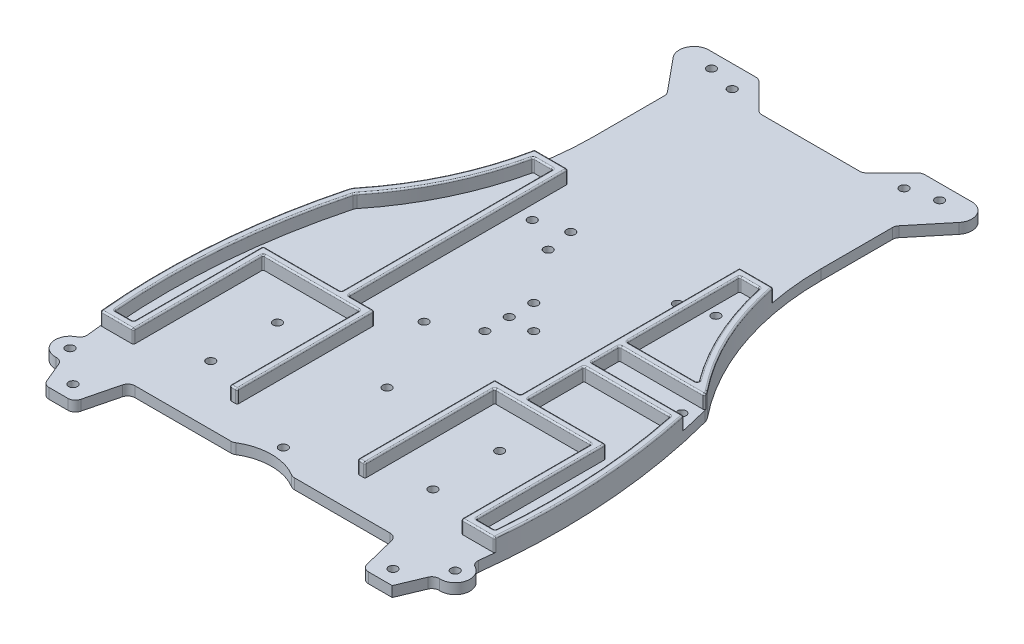
from build123d import *

# Parameters (mm, degrees)
SKETCH1_R                                         = 5
BOSS_EXTRUDE1_DEPTH                               = 8
CSK_FOR_M2_5_FLAT_HEAD_MACHINE_SCREW1_D           = 2.9
CSK_FOR_M2_5_FLAT_HEAD_MACHINE_SCREW1_CSINK_D     = 5.5
CSK_FOR_M2_5_FLAT_HEAD_MACHINE_SCREW1_CSINK_ANGLE = 90
CSK_FOR_M2_5_FLAT_HEAD_MACHINE_SCREW2_D           = 2.9
CSK_FOR_M2_5_FLAT_HEAD_MACHINE_SCREW2_CSINK_D     = 5.5
CSK_FOR_M2_5_FLAT_HEAD_MACHINE_SCREW2_CSINK_ANGLE = 90
FILLET1_R                                         = 2.5
FILLET2_R                                         = 5
CUT_EXTRUDE1_DEPTH                                = 4.5
SKETCH9_R                                         = 1.45
CUT_EXTRUDE3_DEPTH                                = 4.5
FILLET3_R                                         = 0.5


with BuildPart() as part:
    # Sketch1 → Boss-Extrude1 (new body)
    with BuildSketch(Plane(origin=(0, 0, 0), x_dir=(1, 0, 0), z_dir=(0, 1, 0))):
        with Locations((65, -94)):
            Circle(SKETCH1_R)
        with BuildLine():
            Line((58.75, -109), (65, -94))
            ThreePointArc((65, -94), (67.161469468, -48.741029474), (60, -4))
            ThreePointArc((60, -4), (44.037279914, 24.132108636), (38.5, 56))
            Line((38.5, 56), (38.5, 81))
            Line((38.5, 81), (55, 101))
            Line((55, 101), (27.5, 101))
            Line((27.5, 101), (17.5, 91))
            Line((17.5, 91), (0, 91))
            Line((0, 91), (0, -91))
            ThreePointArc((0, -91), (5.220153254, -91.766155818), (10, -94))
            Line((10, -94), (45, -94))
            Line((45, -94), (48.75, -109))
            Line((48.75, -109), (58.75, -109))
        make_face()
    boss_extrude1 = extrude(amount=BOSS_EXTRUDE1_DEPTH)

    # CSK for M2.5 Flat Head Machine Screw1 (through all)
    with Locations(Plane(origin=(0, 0, 0), x_dir=(-1, 0, 0), z_dir=(0, -1, 0))):
        with Locations((-65, -94), (-54, -104), (0, -87), (0, -52), (-37.5, -51.5), (-37.5, -74), (0, -19), (0, -10.75), (0, -2.5), (-24.5, 21.5), (-29, 93.5), (-38.5, 96)):
            csk_for_m2_5_flat_head_machine_screw1 = CounterSinkHole(CSK_FOR_M2_5_FLAT_HEAD_MACHINE_SCREW1_D / 2, CSK_FOR_M2_5_FLAT_HEAD_MACHINE_SCREW1_CSINK_D / 2, counter_sink_angle=CSK_FOR_M2_5_FLAT_HEAD_MACHINE_SCREW1_CSINK_ANGLE)

    # Mirror1: Boss-Extrude1, CSK for M2.5 Flat Head Machine Screw1 across plane
    add(boss_extrude1.mirror(Plane(origin=(0, 0, 0), x_dir=(0, 0, 1), z_dir=(1, 0, 0))))
    add(csk_for_m2_5_flat_head_machine_screw1.mirror(Plane(origin=(0, 0, 0), x_dir=(0, 0, 1), z_dir=(1, 0, 0))), mode=Mode.SUBTRACT)

    # CSK for M2.5 Flat Head Machine Screw2 (through all)
    with Locations(Plane(origin=(0, 0, 0), x_dir=(-1, 0, 0), z_dir=(0, -1, 0))):
        with Locations((-8.25, -10.75), (13, -26.5), (13.1, 15.5), (14.5, 24.5), (-34.5, 24.5), (-57.25, -9.75)):
            CounterSinkHole(CSK_FOR_M2_5_FLAT_HEAD_MACHINE_SCREW2_D / 2, CSK_FOR_M2_5_FLAT_HEAD_MACHINE_SCREW2_CSINK_D / 2, counter_sink_angle=CSK_FOR_M2_5_FLAT_HEAD_MACHINE_SCREW2_CSINK_ANGLE)

    # Fillet1
    fillet1_edges = [part.edges().sort_by_distance(p)[0] for p in [
        (-63.076923077, 4, 98.615384615),
        (-58.75, 4, 109),
        (-48.75, 4, 109),
        (-45, 4, 94),
        (-10, 4, 94),
        (-17.5, 4, -91),
        (-27.5, 4, -101),
        (-38.5, 4, -81),
        (-65.695592958, 4, 89.04862136),
        (48.75, 4, 109),
        (45, 4, 94),
        (10, 4, 94),
        (17.5, 4, -91),
        (27.5, 4, -101),
        (38.5, 4, -81),
        (65.695592958, 4, 89.04862136),
        (63.076923077, 4, 98.615384615),
    ]]
    fillet(fillet1_edges, radius=FILLET1_R)

    # Fillet2
    fillet2_edges = [part.edges().sort_by_distance(p)[0] for p in [
        (-55, 4, -101),
        (-60, 4, 4),
        (55, 4, -101),
        (60, 4, 4),
    ]]
    fillet(fillet2_edges, radius=FILLET2_R)

    # Sketch8 → Cut-Extrude1 (cut)
    with BuildSketch(Plane(origin=(0, 8, 0), x_dir=(1, 0, 0), z_dir=(0, 1, 0))):
        with BuildLine():
            ThreePointArc((-38.5, 56), (-38.93366178, 46.958495647), (-40.230665735, 38))
            Line((-40.230665735, 38), (40.230665735, 38))
            ThreePointArc((40.230665735, 38), (38.93366178, 46.958495647), (38.5, 56))
            Line((38.5, 56), (38.5, 80.10185086))
            ThreePointArc((38.5, 80.10185086), (38.64722685, 80.947107333), (39.071566804, 81.692808247))
            Line((39.071566804, 81.692808247), (48.249920311, 92.818085226))
            ThreePointArc((48.249920311, 92.818085226), (48.915750784, 98.131950531), (44.393053919, 101))
            Line((44.393053919, 101), (28.535533906, 101))
            ThreePointArc((28.535533906, 101), (27.578825325, 100.809698831), (26.767766953, 100.267766953))
            Line((26.767766953, 100.267766953), (18.232233047, 91.732233047))
            ThreePointArc((18.232233047, 91.732233047), (17.421174675, 91.190301169), (16.464466094, 91))
            Line((16.464466094, 91), (-16.464466094, 91))
            ThreePointArc((-16.464466094, 91), (-17.421174675, 91.190301169), (-18.232233047, 91.732233047))
            Line((-18.232233047, 91.732233047), (-26.767766953, 100.267766953))
            ThreePointArc((-26.767766953, 100.267766953), (-27.578825325, 100.809698831), (-28.535533906, 101))
            Line((-28.535533906, 101), (-44.393053919, 101))
            ThreePointArc((-44.393053919, 101), (-48.915750784, 98.131950531), (-48.249920311, 92.818085226))
            Line((-48.249920311, 92.818085226), (-39.071566804, 81.692808247))
            ThreePointArc((-39.071566804, 81.692808247), (-38.64722685, 80.947107333), (-38.5, 80.10185086))
            Line((-38.5, 80.10185086), (-38.5, 56))
        make_face()
    extrude(amount=-CUT_EXTRUDE1_DEPTH, mode=Mode.SUBTRACT)

    # Sketch9 → Cut-Extrude3 (cut)
    with BuildSketch(Plane(origin=(0, 8, 0), x_dir=(1, 0, 0), z_dir=(0, 1, 0))):
        with BuildLine():
            Line((20.332789423, -36), (28.980665735, -36))
            Line((28.980665735, -36), (28.980665735, 38))
            Line((28.980665735, 38), (-28.980665735, 38))
            Line((-28.980665735, 38), (-28.980665735, -36))
            Line((-28.980665735, -36), (-20.332789423, -36))
            Line((-20.332789423, -36), (-20.332789423, -82.25))
            Line((-20.332789423, -82.25), (-22.832789423, -82.25))
            Line((-22.832789423, -82.25), (-22.832789423, -38.5))
            Line((-22.832789423, -38.5), (-55.332789423, -38.5))
            Line((-55.332789423, -38.5), (-55.332789423, -82.25))
            Line((-55.332789423, -82.25), (-66.464655839, -82.25))
            ThreePointArc((-66.464655839, -82.25), (-66.218407293, -84.642779026), (-65.945997096, -87.03272097))
            add(Edge.make_bspline(
                [(-65.945997096, -87.03272097), (-65.931819599, -87.151334825), (-65.924217217, -87.272654234), (-65.923675828, -87.396066101), (-65.930592061, -87.52084183), (-65.945223783, -87.646157242), (-65.990231169, -87.896877325), (-66.020700469, -88.022280978), (-66.059160673, -88.146473288), (-66.10553398, -88.268536553), (-66.159553485, -88.387576343), (-66.28201978, -88.617983577), (-66.350468204, -88.729354092), (-66.425700267, -88.836078322), (-66.507123916, -88.937434656), (-66.594022018, -89.032845213), (-66.776658425, -89.210412573), (-66.872343503, -89.29264642), (-66.971897579, -89.368183185), (-67.074493251, -89.436775533), (-67.179304716, -89.498344615), (-67.285551979, -89.552950175)],
                knots=[0, 0, 0, 0, 0, 0, 0, 0.249259064, 0.249259064, 0.249259064, 0.249259064, 0.249259064, 0.5, 0.5, 0.5, 0.5, 0.5, 0.750740936, 0.750740936, 0.750740936, 0.750740936, 0.750740936, 1, 1, 1, 1, 1, 1, 1], degree=6))
            ThreePointArc((-67.285551979, -89.552950175), (-69.825660331, -95.308817165), (-64.725367228, -98.992451987))
            ThreePointArc((-64.725367228, -98.992451987), (-63.258972452, -99.371238339), (-62.280358534, -100.527139519))
            Line((-62.280358534, -100.527139519), (-59.391025641, -107.461538462))
            ThreePointArc((-59.391025641, -107.461538462), (-58.470083824, -108.580125736), (-57.083333333, -109))
            Line((-57.083333333, -109), (-50.701941016, -109))
            ThreePointArc((-50.701941016, -109), (-49.163410493, -108.470513595), (-48.276584766, -107.106339063))
            Line((-48.276584766, -107.106339063), (-45.473415234, -95.893660937))
            ThreePointArc((-45.473415234, -95.893660937), (-44.586589507, -94.529486405), (-43.048058984, -94))
            Line((-43.048058984, -94), (-10.723805295, -94))
            ThreePointArc((-10.723805295, -94), (-10.050285412, -93.907565361), (-9.426570783, -93.637096774))
            ThreePointArc((-9.426570783, -93.637096774), (0, -91), (9.426570783, -93.637096774))
            ThreePointArc((9.426570783, -93.637096774), (10.050285412, -93.907565361), (10.723805295, -94))
            Line((10.723805295, -94), (43.048058984, -94))
            ThreePointArc((43.048058984, -94), (44.586589507, -94.529486405), (45.473415234, -95.893660937))
            Line((45.473415234, -95.893660937), (48.276584766, -107.106339063))
            ThreePointArc((48.276584766, -107.106339063), (49.163410493, -108.470513595), (50.701941016, -109))
            Line((50.701941016, -109), (58.75, -109))
            Line((58.75, -109), (62.280358534, -100.527139519))
            ThreePointArc((62.280358534, -100.527139519), (63.258972452, -99.371238339), (64.725367228, -98.992451987))
            ThreePointArc((64.725367228, -98.992451987), (69.825660331, -95.308817165), (67.285551979, -89.552950175))
            add(Edge.make_bspline(
                [(67.285551979, -89.552950175), (67.179304716, -89.498344615), (67.074493251, -89.436775533), (66.971897579, -89.368183185), (66.872343503, -89.29264642), (66.776658425, -89.210412573), (66.594022018, -89.032845213), (66.507123916, -88.937434656), (66.425700267, -88.836078322), (66.350468204, -88.729354092), (66.28201978, -88.617983577), (66.159553485, -88.387576343), (66.10553398, -88.268536553), (66.059160673, -88.146473288), (66.020700469, -88.022280978), (65.990231169, -87.896877325), (65.945223783, -87.646157242), (65.930592061, -87.52084183), (65.923675828, -87.396066101), (65.924217217, -87.272654234), (65.931819599, -87.151334825), (65.945997096, -87.03272097)],
                knots=[0, 0, 0, 0, 0, 0, 0, 0.249259064, 0.249259064, 0.249259064, 0.249259064, 0.249259064, 0.5, 0.5, 0.5, 0.5, 0.5, 0.750740936, 0.750740936, 0.750740936, 0.750740936, 0.750740936, 1, 1, 1, 1, 1, 1, 1], degree=6))
            ThreePointArc((65.945997096, -87.03272097), (66.218407293, -84.642779026), (66.464655839, -82.25))
            Line((66.464655839, -82.25), (55.332789423, -82.25))
            Line((55.332789423, -82.25), (55.332789423, -38.5))
            Line((55.332789423, -38.5), (22.832789423, -38.5))
            Line((22.832789423, -38.5), (22.832789423, -82.25))
            Line((22.832789423, -82.25), (20.332789423, -82.25))
            Line((20.332789423, -82.25), (20.332789423, -36))
        make_face()
        with Locations(Location((0, -52, 0), (0, 0, 90))):
            Circle(SKETCH9_R, mode=Mode.SUBTRACT)
        with Locations(Location((-13, -26.5, 0), (0, 0, 90))):
            Circle(SKETCH9_R, mode=Mode.SUBTRACT)
        with Locations(Location((-13.1, 15.5, 0), (0, 0, 90))):
            Circle(SKETCH9_R, mode=Mode.SUBTRACT)
        with Locations(Location((-24.5, 21.5, 0), (0, 0, 90))):
            Circle(SKETCH9_R, mode=Mode.SUBTRACT)
        with Locations(Location((-14.5, 24.5, 0), (0, 0, 90))):
            Circle(SKETCH9_R, mode=Mode.SUBTRACT)
        with Locations(Location((0, -19, 0), (0, 0, 90))):
            Circle(SKETCH9_R, mode=Mode.SUBTRACT)
        with Locations(Location((0, -10.75, 0), (0, 0, 90))):
            Circle(SKETCH9_R, mode=Mode.SUBTRACT)
        with Locations(Location((8.25, -10.75, 0), (0, 0, 90))):
            Circle(SKETCH9_R, mode=Mode.SUBTRACT)
        with Locations(Location((0, -2.5, 0), (0, 0, 90))):
            Circle(SKETCH9_R, mode=Mode.SUBTRACT)
        with Locations(Location((24.5, 21.5, 0), (0, 0, 90))):
            Circle(SKETCH9_R, mode=Mode.SUBTRACT)
        with Locations(Location((65, -94, 0), (0, 0, 90))):
            Circle(SKETCH9_R, mode=Mode.SUBTRACT)
        with Locations(Location((-54, -104, 0), (0, 0, 90))):
            Circle(SKETCH9_R, mode=Mode.SUBTRACT)
        with Locations(Location((-65, -94, 0), (0, 0, 90))):
            Circle(SKETCH9_R, mode=Mode.SUBTRACT)
        with Locations(Location((0, -87, 0), (0, 0, 90))):
            Circle(SKETCH9_R, mode=Mode.SUBTRACT)
        with Locations(Location((54, -104, 0), (0, 0, 90))):
            Circle(SKETCH9_R, mode=Mode.SUBTRACT)
        with Locations(Location((37.5, -51.5, 0), (0, 0, 90))):
            Circle(SKETCH9_R, mode=Mode.SUBTRACT)
        with Locations(Location((37.5, -74, 0), (0, 0, 90))):
            Circle(SKETCH9_R, mode=Mode.SUBTRACT)
        with Locations(Location((-37.5, -51.5, 0), (0, 0, 90))):
            Circle(SKETCH9_R, mode=Mode.SUBTRACT)
        with Locations(Location((-37.5, -74, 0), (0, 0, 90))):
            Circle(SKETCH9_R, mode=Mode.SUBTRACT)
        with BuildLine():
            Line((31.480665735, -17), (31.480665735, -36))
            Line((31.480665735, -36), (57.832789423, -36))
            Line((57.832789423, -36), (57.832789423, -79.75))
            Line((57.832789423, -79.75), (64.184419432, -79.75))
            ThreePointArc((64.184419432, -79.75), (64.628927323, -48.241601045), (60.513206722, -17))
            Line((60.513206722, -17), (31.480665735, -17))
        make_face()
        with BuildLine():
            Line((38.191653436, 35.5), (31.480665735, 35.5))
            Line((31.480665735, 35.5), (31.480665735, -2.5))
            Line((31.480665735, -2.5), (55.633285388, -2.5))
            ThreePointArc((55.633285388, -2.5), (44.840012395, 15.548762302), (38.191653436, 35.5))
        make_face()
        with Locations(Location((34.5, 24.5, 0), (0, 0, 90))):
            Circle(SKETCH9_R, mode=Mode.SUBTRACT)
        with BuildLine():
            Line((31.480665735, -5), (31.480665735, -14.5))
            Line((31.480665735, -14.5), (62.540277173, -14.5))
            ThreePointArc((62.540277173, -14.5), (61.461684719, -9.762400864), (60.278670109, -5.049791854))
            add(Edge.make_bspline(
                [(60.278670109, -5.049791854), (60.276050659, -5.039824786), (60.273404865, -5.029861931), (60.270732733, -5.019903425), (60.268034272, -5.009949402), (60.265309493, -4.999999999)],
                knots=[0, 0, 0, 0, 0, 0, 0.024701767, 0.024701767, 0.024701767, 0.024701767, 0.024701767, 0.024701767], degree=5))
            Line((60.265309489, -5), (31.480665735, -5))
        make_face()
        with Locations(Location((57.25, -9.75, 0), (0, 0, 90))):
            Circle(SKETCH9_R, mode=Mode.SUBTRACT)
        with BuildLine():
            Line((-31.480665735, -36), (-31.480665735, 35.5))
            Line((-31.480665735, 35.5), (-38.191653436, 35.5))
            ThreePointArc((-38.191653436, 35.5), (-45.445876078, 14.254027674), (-57.391394339, -4.754383087))
            ThreePointArc((-57.391394339, -4.754383087), (-57.675145926, -5.195072769), (-57.86077716, -5.68523948))
            ThreePointArc((-57.86077716, -5.68523948), (-64.212001626, -42.445308784), (-64.184419432, -79.75))
            Line((-64.184419432, -79.75), (-57.832789423, -79.75))
            Line((-57.832789423, -79.75), (-57.832789423, -36))
            Line((-57.832789423, -36), (-31.480665735, -36))
        make_face()
    extrude(amount=-CUT_EXTRUDE3_DEPTH, mode=Mode.SUBTRACT)

    # Fillet3
    fillet3_edges = [part.edges().sort_by_distance(p)[0] for p in [
        (-59.907407641, 8, 4.069458433),
        (-47.273987345, 8, -16.240842076),
        (47.273987345, 8, -16.240842076),
        (-34.605665735, 8, -38),
        (-40.230665735, 5.75, -38),
        (40.230665735, 5.75, -38),
        (-45.445876078, 8, -14.254027674),
        (-38.191653436, 5.75, -35.5),
        (-31.480665735, 8, 0.25),
        (-31.480665735, 5.75, -35.5),
        (-44.656727579, 8, 36),
        (-31.480665735, 5.75, 36),
        (-57.832789423, 8, 57.875),
        (-57.832789423, 5.75, 36),
        (-61.008604427, 8, 79.75),
        (-57.832789423, 5.75, 79.75),
        (-64.184419432, 5.75, 79.75),
        (-57.675145926, 8, 5.195072769),
        (-64.212001626, 8, 42.445308784),
        (-34.836159585, 8, -35.5),
        (64.184419432, 5.75, 79.75),
        (57.832789423, 5.75, 79.75),
        (57.832789423, 5.75, 36),
        (31.480665735, 5.75, 36),
        (45.996936229, 8, 17),
        (31.480665735, 5.75, 17),
        (60.513206722, 5.75, 17),
        (61.008604427, 8, 79.75),
        (64.628927323, 8, 48.241601045),
        (31.480665735, 8, 26.5),
        (44.656727579, 8, 36),
        (57.832789423, 8, 57.875),
        (44.840012395, 8, -15.548762302),
        (38.191653436, 5.75, -35.5),
        (55.633285388, 5.75, 2.5),
        (31.480665735, 5.75, 2.5),
        (31.480665735, 5.75, -35.5),
        (34.836159585, 8, -35.5),
        (31.480665735, 8, -16.5),
        (43.556975561, 8, 2.5),
        (34.605665735, 8, -38),
        (-66.797506335, 8, 43.375386069),
        (67.132058507, 8, 48.222682439),
        (60.898722631, 8, 82.25),
        (55.332789423, 5.75, 82.25),
        (66.464655839, 5.75, 82.25),
        (-60.898722631, 8, 82.25),
        (-66.464655839, 5.75, 82.25),
        (-55.332789423, 5.75, 82.25),
        (-39.082789423, 8, 38.5),
        (-55.332789423, 5.75, 38.5),
        (-22.832789423, 8, 60.375),
        (-22.832789423, 5.75, 38.5),
        (-21.582789423, 8, 82.25),
        (-22.832789423, 5.75, 82.25),
        (-20.332789423, 5.75, 82.25),
        (-20.332789423, 5.75, 36),
        (-28.980665735, 5.75, 36),
        (-28.980665735, 5.75, -38),
        (28.980665735, 8, -1),
        (28.980665735, 5.75, -38),
        (24.656727579, 8, 36),
        (28.980665735, 5.75, 36),
        (20.332789423, 8, 59.125),
        (20.332789423, 5.75, 36),
        (21.582789423, 8, 82.25),
        (20.332789423, 5.75, 82.25),
        (22.832789423, 5.75, 82.25),
        (39.082789423, 8, 38.5),
        (22.832789423, 5.75, 38.5),
        (55.332789423, 8, 60.375),
        (55.332789423, 5.75, 38.5),
        (22.832789423, 8, 60.375),
        (-28.980665735, 8, -1),
        (-24.656727579, 8, 36),
        (-20.332789423, 8, 59.125),
        (-55.332789423, 8, 60.375),
        (59.895742505, 8, 4.046472291),
        (62.540277173, 5.75, 14.5),
        (31.480665735, 5.75, 14.5),
        (45.872987612, 8, 5),
        (31.480665735, 5.75, 5),
        (60.265309491, 5.75, 4.999999999),
        (47.010471454, 8, 14.5),
        (31.480665735, 8, 9.75),
    ]]
    fillet(fillet3_edges, radius=FILLET3_R)


solid = part.part
